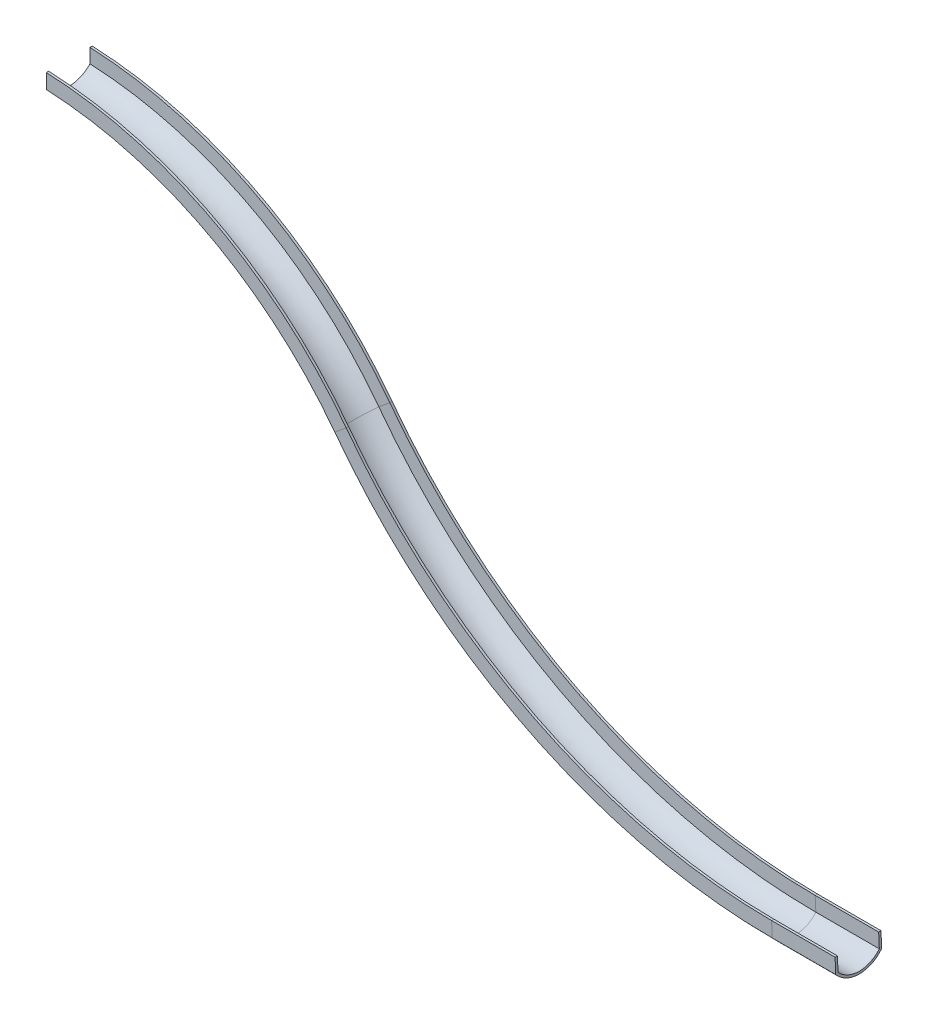
from build123d import *


with BuildPart() as part:
    # Sweep2: sweep along a path in Sketch6
    with BuildLine(Plane.XY) as sweep2_path:
        Line((17000, -8000), (15633.940277982, -8000))
        ThreePointArc((15633.940277982, -8000), (10264.466543366, -6731.670504319), (6030.036461066, -3194.791968878))
        ThreePointArc((6030.036461066, -3194.791968878), (3372.751181533, -922.189974512), (0, 0))
    # Sketch4 → Sweep2 (sweep)
    with BuildSketch(Plane(origin=(0, 0, 0), x_dir=(0, 0, -1), z_dir=(1, 0, 0))):
        with BuildLine():
            Line((-442.401467341, 250.000205972), (-442.401467341, 550.000205972))
            Line((-442.401467341, 550.000205972), (-492.401467341, 550.000205972))
            Line((-492.401467341, 550.000205972), (-492.401467341, 231.338415128))
            ThreePointArc((-492.401467341, 231.338415128), (0, 0), (495.783903942, 223.997740939))
            Line((495.783903942, 223.997740939), (495.783903942, 550.000205972))
            Line((495.783903942, 550.000205972), (445.783903942, 550.000205972))
            Line((445.783903942, 550.000205972), (445.783903942, 243.093628659))
            ThreePointArc((445.783903942, 243.093628659), (0.162860481, 50.000205972), (-442.401467341, 250.000205972))
        make_face()
    sweep(path=sweep2_path.line)


solid = part.part
